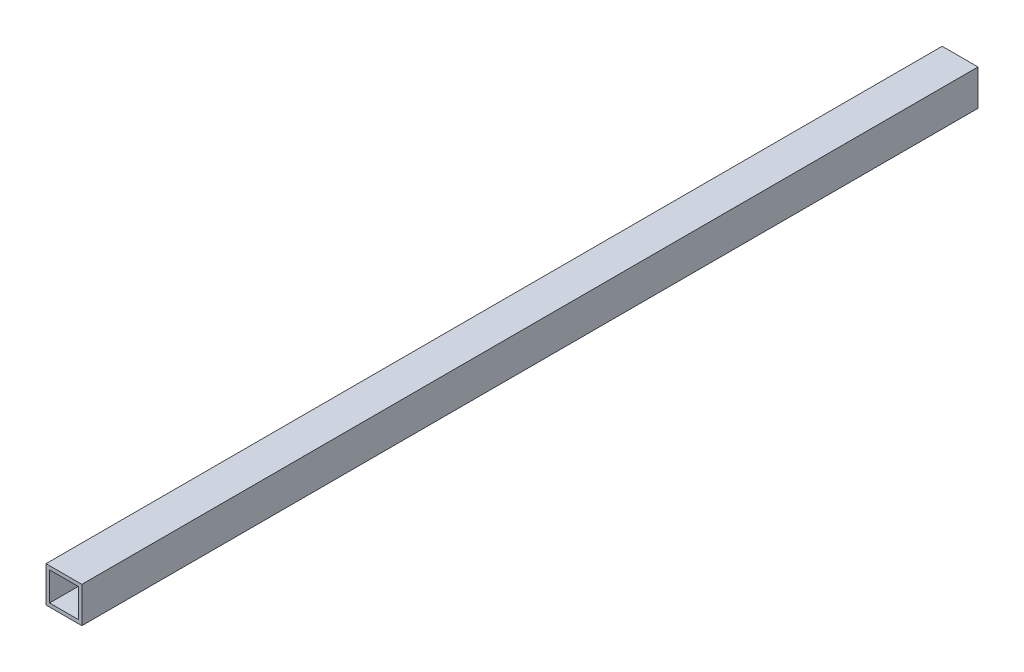
from build123d import *

# Parameters (mm, degrees)
SKETCH1_W           = 20
SKETCH1_H           = 20
SKETCH1_W_2         = 16
SKETCH1_H_2         = 16
BOSS_EXTRUDE1_DEPTH = 500


with BuildPart() as part:
    # Sketch1 → Boss-Extrude1 (new body)
    with BuildSketch(Plane.XY):
        Rectangle(SKETCH1_W, SKETCH1_H)
        Rectangle(SKETCH1_W_2, SKETCH1_H_2, mode=Mode.SUBTRACT)
    extrude(amount=BOSS_EXTRUDE1_DEPTH)


solid = part.part
